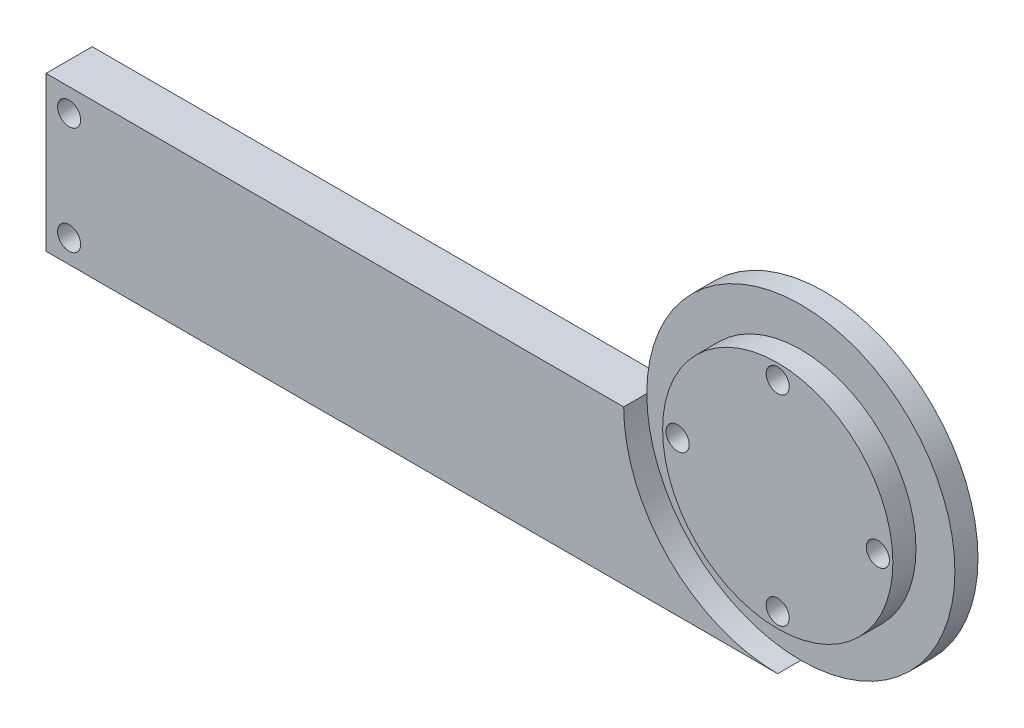
from build123d import *

# Parameters (mm, degrees)
BOSS_EXTRU_1_DEPTH      = 6
ESQUISSE4_R             = 20
ESQUISSE4_R_2           = 14.95
ENL_V_MAT_EXTRU_2_DEPTH = 3
ESQUISSE5_W             = 16.42
ESQUISSE5_H             = 20
BOSS_EXTRU_2_DEPTH      = 6
ESQUISSE6_R             = 1.5
ENL_V_MAT_EXTRU_3_DEPTH = 10
ESQUISSE9_R             = 1.5
ENL_V_MAT_EXTRU_4_DEPTH = 10


with BuildPart() as part:
    # Esquisse1 → Boss.-Extru.1 (new body)
    with BuildSketch(Plane.XY):
        with BuildLine():
            ThreePointArc((52.992232765, 28.099272116), (32.992232765, 48.099272116), (12.992232765, 28.099272116))
            Line((12.992232765, 28.099272116), (32.992232765, 28.099272116))
            Line((32.992232765, 28.099272116), (32.992232765, 8.099272116))
            ThreePointArc((32.992232765, 8.099272116), (47.134368389, 13.957136493), (52.992232765, 28.099272116))
        make_face()
        with BuildLine():
            Line((32.992232765, 28.099272116), (12.992232765, 28.099272116))
            ThreePointArc((12.992232765, 28.099272116), (18.850097141, 13.957136493), (32.992232765, 8.099272116))
            Line((32.992232765, 8.099272116), (32.992232765, 28.099272116))
        make_face()
        with BuildLine():
            Line((12.992232765, 28.099272116), (-45.58279523, 28.099272116))
            Line((-45.58279523, 28.099272116), (-45.58279523, 8.099272116))
            Line((-45.58279523, 8.099272116), (32.992232765, 8.099272116))
            ThreePointArc((32.992232765, 8.099272116), (18.850097141, 13.957136493), (12.992232765, 28.099272116))
        make_face()
    extrude(amount=BOSS_EXTRU_1_DEPTH)

    # Esquisse4 → Enlèv. mat.-Extru.2 (cut)
    with BuildSketch(Plane.XY.offset(6)):
        with Locations((32.992232765, 28.099272116)):
            Circle(ESQUISSE4_R)
        with Locations((32.992232765, 28.099272116)):
            Circle(ESQUISSE4_R_2, mode=Mode.SUBTRACT)
    extrude(amount=-ENL_V_MAT_EXTRU_2_DEPTH, mode=Mode.SUBTRACT)

    # Esquisse5 → Boss.-Extru.2 (add)
    with BuildSketch(Plane.XY.offset(6)):
        with Locations((-53.79279523, 18.099272116)):
            Rectangle(ESQUISSE5_W, ESQUISSE5_H)
    extrude(amount=-BOSS_EXTRU_2_DEPTH)

    # Esquisse6 → Enlèv. mat.-Extru.3 (cut)
    with BuildSketch(Plane.XY.offset(6)):
        with Locations((32.992232765, 41.099272116)):
            Circle(ESQUISSE6_R)
        with Locations((45.992232765, 28.099272116)):
            Circle(ESQUISSE6_R)
        with Locations((32.992232765, 15.099272116)):
            Circle(ESQUISSE6_R)
        with Locations((19.992232765, 28.099272116)):
            Circle(ESQUISSE6_R)
    extrude(amount=-ENL_V_MAT_EXTRU_3_DEPTH, mode=Mode.SUBTRACT)

    # Esquisse9 → Enlèv. mat.-Extru.4 (cut)
    with BuildSketch(Plane(origin=(0, 0, 0), x_dir=(-1, 0, 0), z_dir=(0, 0, -1))):
        with Locations((59.00279523, 25.099272116)):
            Circle(ESQUISSE9_R)
        with Locations((59.00279523, 11.099272116)):
            Circle(ESQUISSE9_R)
    extrude(amount=-ENL_V_MAT_EXTRU_4_DEPTH, mode=Mode.SUBTRACT)


solid = part.part
